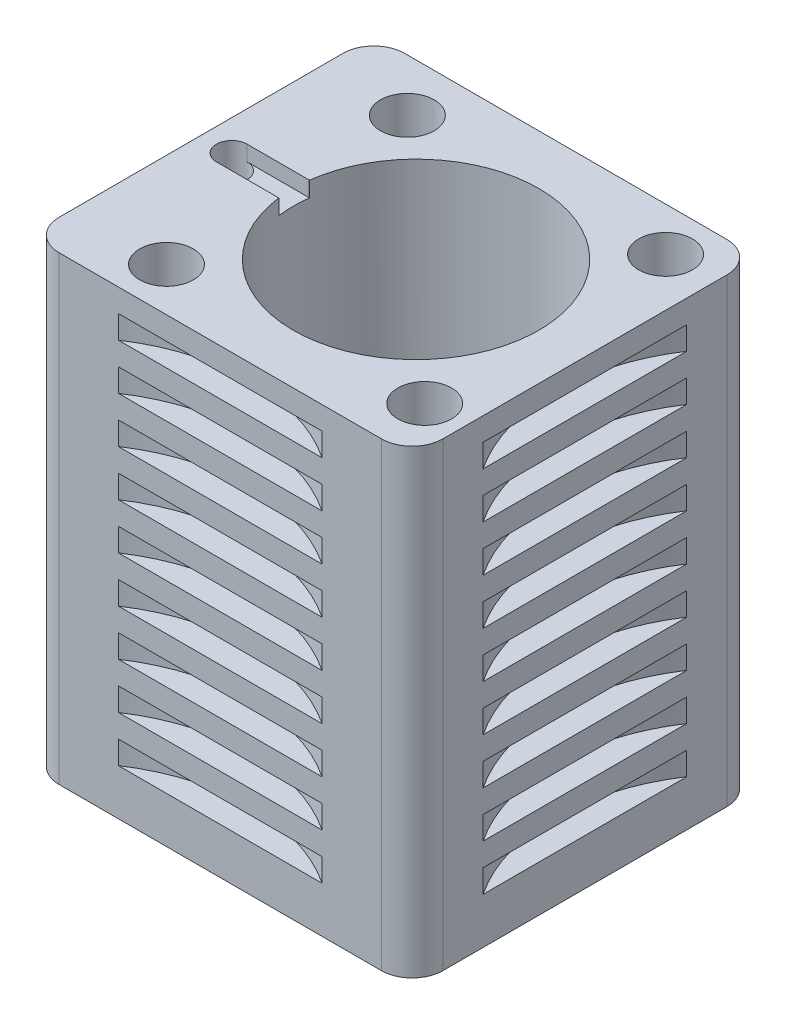
from build123d import *

# Parameters (mm, degrees)
SKETCH1_R               = 3.5
SKETCH1_R_2             = 16
BOSS_EXTRUDE2_DEPTH     = 60
CUT_EXTRUDE6_DEPTH      = 1
CUT_EXTRUDE6_DEPTH_BACK = 2
SKETCH7_R               = 2
CUT_EXTRUDE7_DEPTH      = 59
SKETCH8_R               = 18
SKETCH8_R_2             = 16
BOSS_EXTRUDE3_DEPTH     = 2
CUT_EXTRUDE8_START      = 6
SKETCH9_R               = 24
CUT_EXTRUDE8_DEPTH      = 3
LPATTERN1_COUNT         = 9
LPATTERN1_PITCH         = 6


with BuildPart() as part:
    # Sketch1 → Boss-Extrude2 (new body)
    with BuildSketch(Plane(origin=(0, 0, 0), x_dir=(1, 0, 0), z_dir=(0, 1, 0))):
        with BuildLine():
            Line((-21, -22.5), (21, -22.5))
            ThreePointArc((21, -22.5), (23.828427125, -21.328427125), (25, -18.5))
            Line((25, -18.5), (25, 18.5))
            ThreePointArc((25, 18.5), (23.828427125, 21.328427125), (21, 22.5))
            Line((21, 22.5), (-21, 22.5))
            ThreePointArc((-21, 22.5), (-23.828427125, 21.328427125), (-25, 18.5))
            Line((-25, 18.5), (-25, -18.5))
            ThreePointArc((-25, -18.5), (-23.828427125, -21.328427125), (-21, -22.5))
        make_face()
        with Locations((18.688018935, 16.819217042)):
            Circle(SKETCH1_R, mode=Mode.SUBTRACT)
        with Locations((19.819217042, -15.688018935)):
            Circle(SKETCH1_R, mode=Mode.SUBTRACT)
        with Locations((-12.688018935, -16.819217042)):
            Circle(SKETCH1_R, mode=Mode.SUBTRACT)
        with Locations((-13.819217042, 15.688018935)):
            Circle(SKETCH1_R, mode=Mode.SUBTRACT)
        with Locations((3, 0)):
            Circle(SKETCH1_R_2, mode=Mode.SUBTRACT)
    extrude(amount=BOSS_EXTRUDE2_DEPTH)

    # Sketch6 → Cut-Extrude6 (cut, two sides)
    with BuildSketch(Plane(origin=(0, 60, 0), x_dir=(1, 0, 0), z_dir=(0, 1, 0))) as cut_extrude6_sk:
        with BuildLine():
            Line((-13, 2), (-21, 2))
            ThreePointArc((-21, 2), (-23, 0), (-21, -2))
            Line((-21, -2), (-13, -2))
            ThreePointArc((-13, -2), (-12.93746943, -1.999022243), (-12.875, -1.996089928))
            ThreePointArc((-12.875, -1.996089928), (-13, 0), (-12.875, 1.996089928))
            ThreePointArc((-12.875, 1.996089928), (-12.93746943, 1.999022243), (-13, 2))
        make_face()
    extrude(amount=CUT_EXTRUDE6_DEPTH, mode=Mode.SUBTRACT)
    extrude(cut_extrude6_sk.sketch, amount=-CUT_EXTRUDE6_DEPTH_BACK, mode=Mode.SUBTRACT)

    # Sketch7 → Cut-Extrude7 (cut, through all)
    with BuildSketch(Plane(origin=(0, 58, 0), x_dir=(1, 0, 0), z_dir=(0, 1, 0))):
        with Locations((-21, 0)):
            Circle(SKETCH7_R)
    extrude(amount=-CUT_EXTRUDE7_DEPTH, mode=Mode.SUBTRACT)

    # Sketch8 → Boss-Extrude3 (add)
    with BuildSketch(Plane.XZ):
        with Locations((3, 0)):
            Circle(SKETCH8_R)
        with Locations((3, 0)):
            Circle(SKETCH8_R_2, mode=Mode.SUBTRACT)
    extrude(amount=BOSS_EXTRUDE3_DEPTH)

    # Sketch9 → Cut-Extrude8 (cut)
    with BuildSketch(Plane(origin=(0, 0, 0), x_dir=(1, 0, 0), z_dir=(0, 1, 0)).offset(CUT_EXTRUDE8_START)):
        with Locations((45, 0)):
            Circle(SKETCH9_R)
        with Locations((0, 42.5)):
            Circle(SKETCH9_R)
        with Locations((0, -42.5)):
            Circle(SKETCH9_R)
    cut_extrude8 = extrude(amount=CUT_EXTRUDE8_DEPTH, mode=Mode.SUBTRACT)

    # LPattern1: Cut-Extrude8 ×9
    with Locations(*[(0, i * LPATTERN1_PITCH, 0) for i in range(1, LPATTERN1_COUNT)]):
        add(cut_extrude8, mode=Mode.SUBTRACT)


solid = part.part
